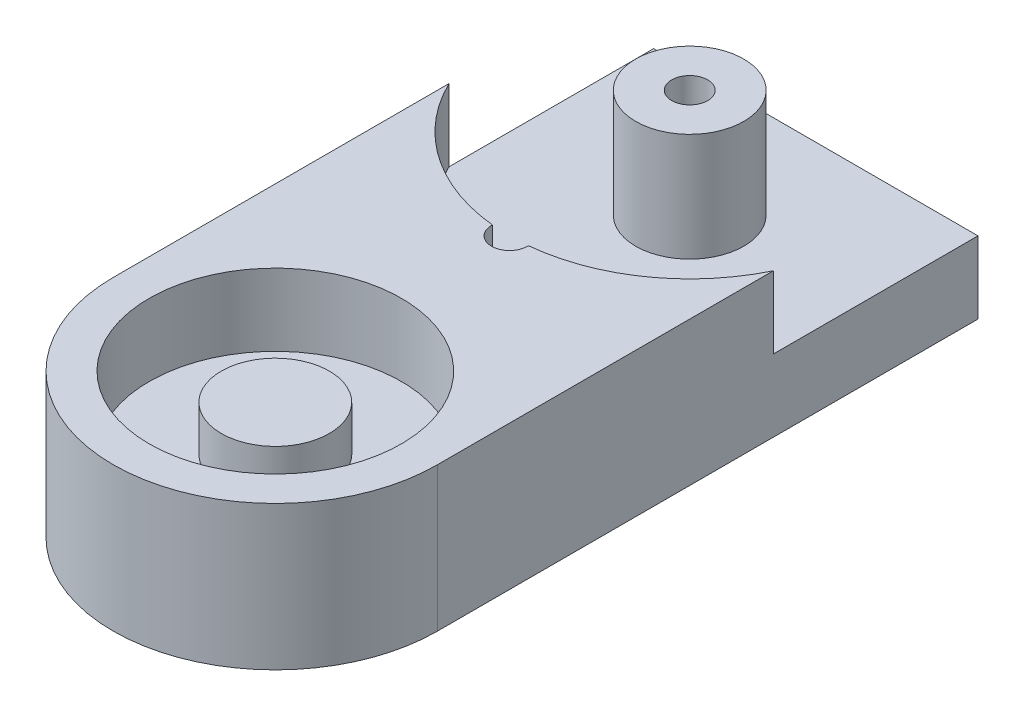
from build123d import *

# Parameters (mm, degrees)
SKETCH1_R           = 1
BOSS_EXTRUDE1_DEPTH = 8
SKETCH2_R           = 7
SKETCH2_R_2         = 3
CUT_EXTRUDE1_DEPTH  = 4
SKETCH3_R           = 3
CUT_EXTRUDE2_DEPTH  = 1.5
CUT_EXTRUDE3_DEPTH  = 4
BOSS_EXTRUDE2_START = -10
SKETCH5_W           = 30
SKETCH5_H           = 2
BOSS_EXTRUDE2_DEPTH = 2
SKETCH6_R           = 3
SKETCH6_R_2         = 1
BOSS_EXTRUDE3_DEPTH = 6
SKETCH7_R           = 1
CUT_EXTRUDE4_DEPTH  = 5


with BuildPart() as part:
    # Sketch1 → Boss-Extrude1 (new body)
    with BuildSketch(Plane(origin=(0, 0, 0), x_dir=(1, 0, 0), z_dir=(0, 1, 0))):
        with BuildLine():
            Line((-3, 53.504881109), (15, 53.504881109))
            Line((15, 53.504881109), (15, 23.504881109))
            ThreePointArc((15, 23.504881109), (6, 14.504881109), (-3, 23.504881109))
            Line((-3, 23.504881109), (-3, 53.504881109))
        make_face()
        with Locations((6, 36.504881109)):
            Circle(SKETCH1_R, mode=Mode.SUBTRACT)
        with Locations((6, 46.504881109)):
            Circle(SKETCH1_R, mode=Mode.SUBTRACT)
    extrude(amount=BOSS_EXTRUDE1_DEPTH)

    # Sketch2 → Cut-Extrude1 (cut)
    with BuildSketch(Plane(origin=(0, 8, 0), x_dir=(1, 0, 0), z_dir=(0, 1, 0))):
        with Locations((6, 23.504881109)):
            Circle(SKETCH2_R)
        with Locations((6, 23.504881109)):
            Circle(SKETCH2_R_2, mode=Mode.SUBTRACT)
    extrude(amount=-CUT_EXTRUDE1_DEPTH, mode=Mode.SUBTRACT)

    # Sketch3 → Cut-Extrude2 (cut)
    with BuildSketch(Plane(origin=(0, 8, 0), x_dir=(1, 0, 0), z_dir=(0, 1, 0))):
        with Locations((6, 23.504881109)):
            Circle(SKETCH3_R)
    extrude(amount=-CUT_EXTRUDE2_DEPTH, mode=Mode.SUBTRACT)

    # Sketch4 → Cut-Extrude3 (cut)
    with BuildSketch(Plane(origin=(0, 8, 0), x_dir=(1, 0, 0), z_dir=(0, 1, 0))):
        with BuildLine():
            Line((-4, 46.504881109), (-4, 53.993644797))
            Line((-4, 53.993644797), (16, 53.993644797))
            Line((16, 53.993644797), (16, 46.504881109))
            ThreePointArc((16, 46.504881109), (6, 36.504881109), (-4, 46.504881109))
        make_face()
    extrude(amount=-CUT_EXTRUDE3_DEPTH, mode=Mode.SUBTRACT)

    # Sketch5 → Boss-Extrude2 (add)
    with BuildSketch(Plane(origin=(15, 0, 0), x_dir=(0, 0, -1), z_dir=(1, 0, 0)).offset(BOSS_EXTRUDE2_START)):
        with Locations((38.504881109, 1)):
            Rectangle(SKETCH5_W, SKETCH5_H)
    extrude(amount=BOSS_EXTRUDE2_DEPTH)

    # Sketch6 → Boss-Extrude3 (add)
    with BuildSketch(Plane(origin=(0, 4, 0), x_dir=(1, 0, 0), z_dir=(0, 1, 0))):
        with Locations((6, 46.504881109)):
            Circle(SKETCH6_R)
        with Locations((6, 46.504881109)):
            Circle(SKETCH6_R_2, mode=Mode.SUBTRACT)
    extrude(amount=BOSS_EXTRUDE3_DEPTH)

    # Sketch7 → Cut-Extrude4 (cut)
    with BuildSketch(Plane(origin=(0, 0, -53.504881109), x_dir=(-1, 0, 0), z_dir=(0, 0, -1))):
        with Locations((-12, 2)):
            Circle(SKETCH7_R)
        with Locations((0, 2)):
            Circle(SKETCH7_R)
    extrude(amount=-CUT_EXTRUDE4_DEPTH, mode=Mode.SUBTRACT)


solid = part.part
